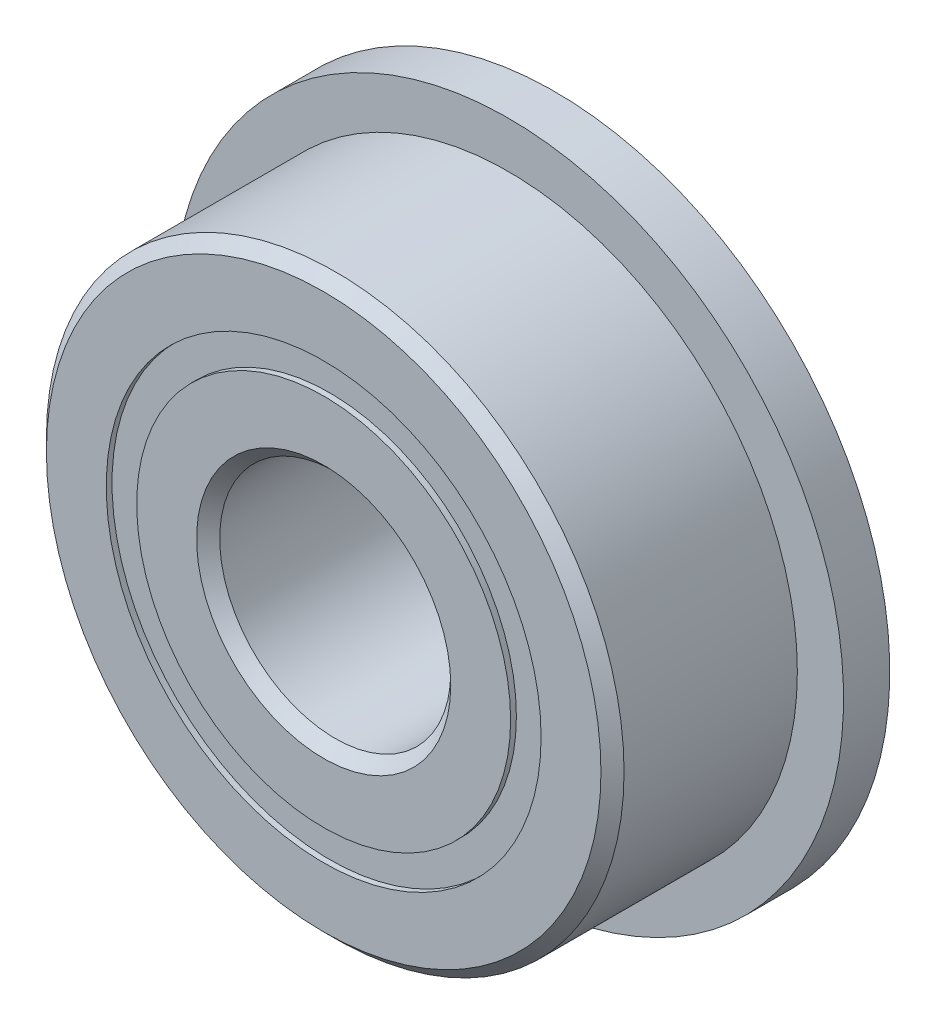
from build123d import *

# Parameters (mm, degrees)
CIRPATTERN1_COUNT = 12
SKETCH5_W         = 0.972810551
SKETCH5_H         = 0.527472528
SKETCH6_W         = 0.8
SKETCH6_H         = 2.036263736


with BuildPart() as part:
    # Sketch1 → Revolve1 (revolve)
    with BuildSketch(Plane(origin=(0, 0, 0), x_dir=(0, 0, -1), z_dir=(1, 0, 0))):
        with BuildLine():
            Line((1.8, 5), (-1.8, 5))
            Line((-1.8, 5), (-2, 4.8))
            Line((-2, 4.8), (-2, 3.763736264))
            Line((-2, 3.763736264), (-0.888888889, 3.763736264))
            ThreePointArc((-0.888888889, 3.763736264), (0, 4.427189449), (0.888888889, 3.763736264))
            Line((0.888888889, 3.763736264), (2, 3.763736264))
            Line((2, 3.763736264), (2, 4.8))
            Line((2, 4.8), (1.8, 5))
        make_face()
    revolve(axis=Axis((0, 0, 2), (0, 0, -1)))

    # Sketch6 → Revolve6 (revolve)
    with BuildSketch(Plane(origin=(0, 0, 0), x_dir=(0, 0, -1), z_dir=(1, 0, 0))):
        with Locations((1.6, 4.781868132)):
            Rectangle(SKETCH6_W, SKETCH6_H)
    revolve(axis=Axis((0, 0, -2), (0, 0, 1)))


with BuildPart() as body_2:
    # Sketch3 → Revolve3 (revolve)
    with BuildSketch(Plane(origin=(0, 0, 0), x_dir=(0, 0, -1), z_dir=(1, 0, 0))):
        with BuildLine():
            Line((-2, 3.236263736), (-0.888888889, 3.236263736))
            ThreePointArc((-0.888888889, 3.236263736), (0, 2.572810551), (0.888888889, 3.236263736))
            Line((0.888888889, 3.236263736), (2, 3.236263736))
            Line((2, 3.236263736), (2, 2.2))
            Line((2, 2.2), (1.8, 2))
            Line((1.8, 2), (-1.8, 2))
            Line((-1.8, 2), (-2, 2.2))
            Line((-2, 2.2), (-2, 3.236263736))
        make_face()
    revolve(axis=Axis((0, 0, 2), (0, 0, -1)))


with BuildPart() as body_3:
    # Sketch4 → Revolve4 (revolve)
    with BuildSketch(Plane(origin=(0, 0, 0), x_dir=(0, 0, -1), z_dir=(1, 0, 0))):
        with BuildLine():
            Line((-0.927189449, 3.5), (0.927189449, 3.5))
            ThreePointArc((0.927189449, 3.5), (0, 4.427189449), (-0.927189449, 3.5))
        make_face()
    revolve(axis=Axis((0, 3.5, 0.927189449), (0, 0, -1)))


with BuildPart() as cirpattern1_1:
    # CirPattern1: pattern copy
    add(body_3.part.rotate(Axis((0, 0, 0), (0, 0, 1)), 1 * 360 / CIRPATTERN1_COUNT))


with BuildPart() as cirpattern1_2:
    # CirPattern1: pattern copy
    add(body_3.part.rotate(Axis((0, 0, 0), (0, 0, 1)), 2 * 360 / CIRPATTERN1_COUNT))


with BuildPart() as cirpattern1_3:
    # CirPattern1: pattern copy
    add(body_3.part.rotate(Axis((0, 0, 0), (0, 0, 1)), 3 * 360 / CIRPATTERN1_COUNT))


with BuildPart() as cirpattern1_4:
    # CirPattern1: pattern copy
    add(body_3.part.rotate(Axis((0, 0, 0), (0, 0, 1)), 4 * 360 / CIRPATTERN1_COUNT))


with BuildPart() as cirpattern1_5:
    # CirPattern1: pattern copy
    add(body_3.part.rotate(Axis((0, 0, 0), (0, 0, 1)), 5 * 360 / CIRPATTERN1_COUNT))


with BuildPart() as cirpattern1_6:
    # CirPattern1: pattern copy
    add(body_3.part.rotate(Axis((0, 0, 0), (0, 0, 1)), 6 * 360 / CIRPATTERN1_COUNT))


with BuildPart() as cirpattern1_7:
    # CirPattern1: pattern copy
    add(body_3.part.rotate(Axis((0, 0, 0), (0, 0, 1)), 7 * 360 / CIRPATTERN1_COUNT))


with BuildPart() as cirpattern1_8:
    # CirPattern1: pattern copy
    add(body_3.part.rotate(Axis((0, 0, 0), (0, 0, 1)), 8 * 360 / CIRPATTERN1_COUNT))


with BuildPart() as cirpattern1_9:
    # CirPattern1: pattern copy
    add(body_3.part.rotate(Axis((0, 0, 0), (0, 0, 1)), 9 * 360 / CIRPATTERN1_COUNT))


with BuildPart() as cirpattern1_10:
    # CirPattern1: pattern copy
    add(body_3.part.rotate(Axis((0, 0, 0), (0, 0, 1)), 10 * 360 / CIRPATTERN1_COUNT))


with BuildPart() as cirpattern1_11:
    # CirPattern1: pattern copy
    add(body_3.part.rotate(Axis((0, 0, 0), (0, 0, 1)), 11 * 360 / CIRPATTERN1_COUNT))


with BuildPart() as body_15:
    # Sketch5 → Revolve5 (revolve)
    with BuildSketch(Plane(origin=(0, 0, 0), x_dir=(0, 0, -1), z_dir=(1, 0, 0))):
        with Locations((-1.413594725, 3.5)):
            Rectangle(SKETCH5_W, SKETCH5_H)
        with Locations((1.413594725, 3.5)):
            Rectangle(SKETCH5_W, SKETCH5_H)
    revolve(axis=Axis((0, 0, 2), (0, 0, -1)))


solid = Compound([part.part, body_2.part, body_3.part, cirpattern1_1.part, cirpattern1_2.part, cirpattern1_3.part, cirpattern1_4.part, cirpattern1_5.part, cirpattern1_6.part, cirpattern1_7.part, cirpattern1_8.part, cirpattern1_9.part, cirpattern1_10.part, cirpattern1_11.part, body_15.part])
